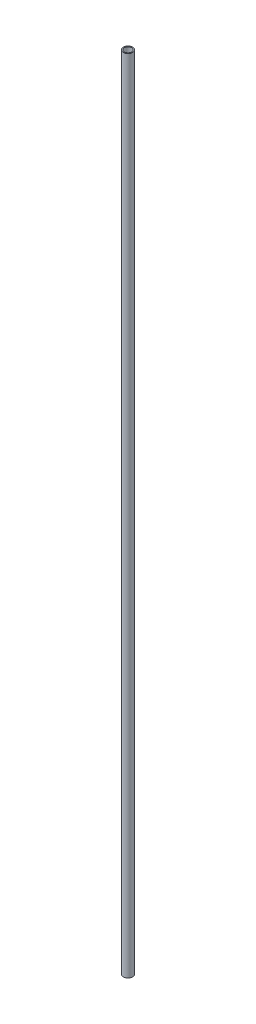
from build123d import *

# Parameters (mm, degrees)
SKETCH1_R           = 3.6195
SKETCH1_R_2         = 2.8575
BOSS_EXTRUDE1_DEPTH = 622.3


with BuildPart() as part:
    # Sketch1 → Boss-Extrude1 (new body)
    with BuildSketch(Plane(origin=(0, 0, 0), x_dir=(1, 0, 0), z_dir=(0, 1, 0))):
        Circle(SKETCH1_R)
        Circle(SKETCH1_R_2, mode=Mode.SUBTRACT)
    extrude(amount=BOSS_EXTRUDE1_DEPTH)


solid = part.part
